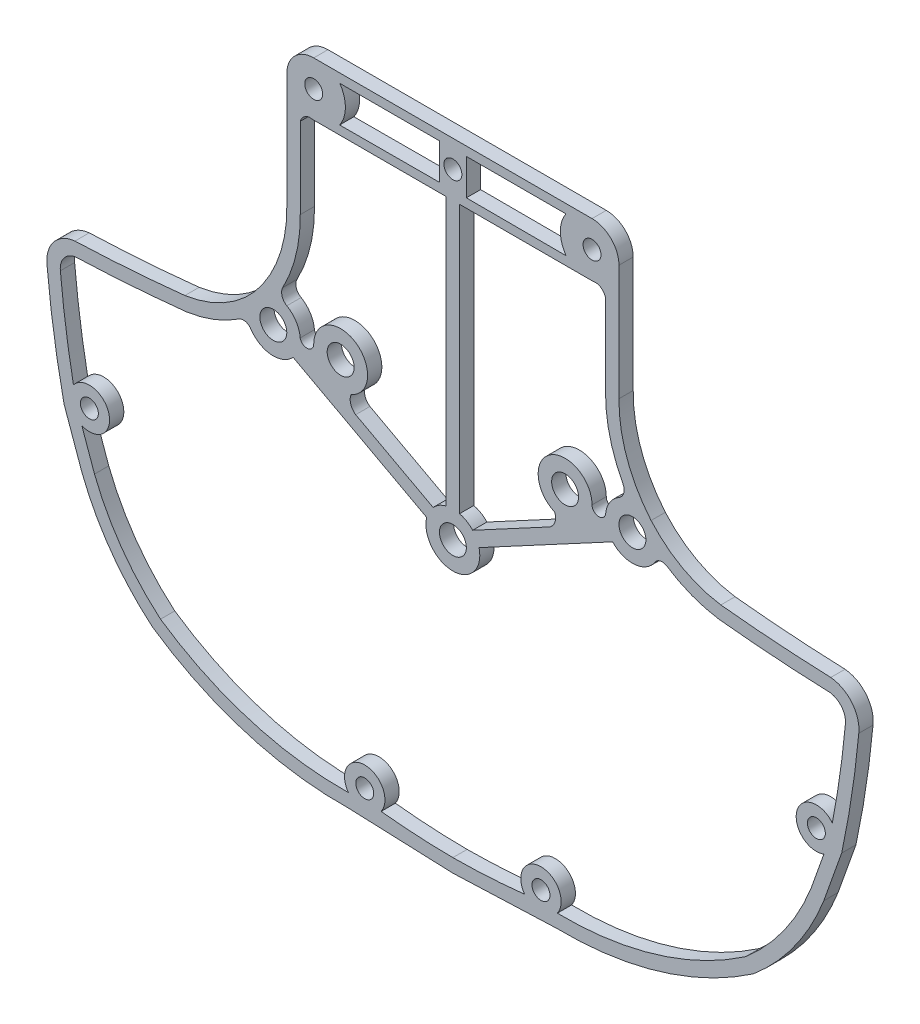
from build123d import *

# Parameters (mm, degrees)
SKETCH4_R           = 1
SKETCH4_R_2         = 1.5
SKETCH4_R_3         = 1.500000001
BOSS_EXTRUDE2_DEPTH = 1.5875


with BuildPart() as part:
    # Sketch4 → Boss-Extrude2 (new body)
    with BuildSketch(Plane.XY):
        with BuildLine():
            ThreePointArc((-33.472754103, -25.121469845), (-23.054804413, -30.112701264), (-11.610361031, -31.68457355))
            Line((-11.610361031, -31.68457355), (0, -32.144613372))
            Line((0, -32.144613372), (11.610361031, -31.68457355))
            ThreePointArc((11.610361031, -31.68457355), (23.054804413, -30.112701264), (33.472754103, -25.121469845))
            ThreePointArc((33.472754103, -25.121469845), (38.084735692, -20.128369992), (41.315395383, -14.148047401))
            Line((41.315395383, -14.148047401), (43.310324676, -8.545068137))
            ThreePointArc((43.310324676, -8.545068137), (44.448650445, -2.324461154), (45.212741618, 3.953110149))
            ThreePointArc((45.212741618, 3.953110149), (44.453814547, 6.519739723), (42.09374947, 7.782138432))
            ThreePointArc((42.09374947, 7.782138432), (35.962680023, 8.111048014), (29.846780415, 8.653234381))
            ThreePointArc((29.846780415, 8.653234381), (25.580679905, 10.088760175), (22.077124707, 12.914613823))
            ThreePointArc((22.077124707, 12.914613823), (19.390258386, 17.570844388), (18.500000009, 22.872464303))
            Line((18.500000009, 22.872464303), (18.500000009, 35.75))
            ThreePointArc((18.500000009, 35.75), (17.62132035, 37.87132035), (15.5, 38.750000009))
            Line((15.5, 38.750000009), (-15.5, 38.750000009))
            ThreePointArc((-15.5, 38.750000009), (-17.62132035, 37.87132035), (-18.500000009, 35.75))
            Line((-18.500000009, 35.75), (-18.500000009, 22.872464277))
            ThreePointArc((-18.500000009, 22.872464277), (-19.390258383, 17.570844381), (-22.07712469, 12.91461383))
            ThreePointArc((-22.07712469, 12.91461383), (-25.580679805, 10.088760216), (-29.846780215, 8.653234395))
            ThreePointArc((-29.846780215, 8.653234395), (-35.962679941, 8.111048017), (-42.093749505, 7.78213843))
            ThreePointArc((-42.093749505, 7.78213843), (-44.453814559, 6.519739711), (-45.212741618, 3.953110149))
            ThreePointArc((-45.212741618, 3.953110149), (-44.448650445, -2.324461154), (-43.310324676, -8.545068137))
            Line((-43.310324676, -8.545068137), (-41.315395383, -14.148047401))
            ThreePointArc((-41.315395383, -14.148047401), (-38.084735692, -20.128369992), (-33.472754103, -25.121469845))
        make_face()
        with Locations((-9.815163292, -28.866300371)):
            Circle(SKETCH4_R, mode=Mode.SUBTRACT)
        with Locations((-40.488991371, -7.557479081)):
            Circle(SKETCH4_R, mode=Mode.SUBTRACT)
        with BuildLine():
            Line((-39.916947455, -13.605513167), (-41.326325711, -9.6458687))
            ThreePointArc((-41.326325711, -9.6458687), (-38.316546684, -6.971830651), (-42.262559751, -6.172937569))
            ThreePointArc((-42.262559751, -6.172937569), (-43.119549374, -1.052504396), (-43.720300768, 4.104274139))
            ThreePointArc((-43.720300768, 4.104274139), (-43.306279922, 5.553180603), (-41.988991391, 6.284955247))
            ThreePointArc((-41.988991391, 6.284955247), (-35.815859297, 6.617706074), (-29.658025423, 7.164848598))
            ThreePointArc((-29.658025423, 7.164848598), (-26.630229039, 7.954390182), (-23.847155024, 9.384574043))
            ThreePointArc((-23.847155024, 9.384574043), (-23.125480938, 9.525676377), (-22.515405804, 9.115150267))
            ThreePointArc((-22.515405804, 9.115150267), (-20.254015304, 7.760773306), (-17.79651867, 8.714153732))
            Line((-17.79651867, 8.714153732), (-2.913646, 0.714609672))
            ThreePointArc((-2.913646, 0.714609672), (0, -3), (2.913646001, 0.714609672))
            Line((2.913646001, 0.714609672), (17.79651867, 8.714153732))
            ThreePointArc((17.79651867, 8.714153732), (20.254015126, 7.760773292), (22.515405609, 9.115149969))
            ThreePointArc((22.515405609, 9.115149969), (23.125480765, 9.52567634), (23.847155026, 9.384574041))
            ThreePointArc((23.847155026, 9.384574041), (26.630229041, 7.954390183), (29.658025423, 7.164848601))
            ThreePointArc((29.658025423, 7.164848601), (35.815859287, 6.617706075), (41.988991371, 6.284955244))
            ThreePointArc((41.988991371, 6.284955244), (43.306279914, 5.553180608), (43.720300768, 4.104274139))
            ThreePointArc((43.720300768, 4.104274139), (43.119549374, -1.052504396), (42.262559751, -6.172937569))
            ThreePointArc((42.262559751, -6.172937569), (38.316546684, -6.971830651), (41.326325712, -9.6458687))
            Line((41.326325712, -9.6458687), (39.916947456, -13.605513167))
            ThreePointArc((39.916947456, -13.605513167), (36.88563151, -19.226390572), (32.562542901, -23.926820768))
            ThreePointArc((32.562542901, -23.926820768), (22.58818115, -28.686629582), (11.638338487, -30.184834485))
            ThreePointArc((11.638338487, -30.184834485), (9.815163292, -26.616300371), (7.991988098, -30.184834485))
            ThreePointArc((7.991988098, -30.184834485), (4.00190894, -30.517536934), (0, -30.644609524))
            ThreePointArc((0, -30.644609524), (-4.00190894, -30.517536934), (-7.991988097, -30.184834485))
            ThreePointArc((-7.991988097, -30.184834485), (-9.815163292, -26.616300371), (-11.638338487, -30.184834485))
            ThreePointArc((-11.638338487, -30.184834485), (-22.58818115, -28.686629582), (-32.562542901, -23.926820768))
            ThreePointArc((-32.562542901, -23.926820768), (-36.88563151, -19.226390572), (-39.916947455, -13.605513167))
        make_face(mode=Mode.SUBTRACT)
        with Locations((9.815163292, -28.866300371)):
            Circle(SKETCH4_R, mode=Mode.SUBTRACT)
        Circle(SKETCH4_R_2, mode=Mode.SUBTRACT)
        with Locations((40.488991371, -7.557479081)):
            Circle(SKETCH4_R, mode=Mode.SUBTRACT)
        with Locations((-20.000000001, 10.750000001)):
            Circle(SKETCH4_R_3, mode=Mode.SUBTRACT)
        with Locations((-12.5, 11.133699629)):
            Circle(SKETCH4_R_2, mode=Mode.SUBTRACT)
        with BuildLine():
            ThreePointArc((-18.952977672, 14.865256843), (-17.471741936, 18.750329795), (-17.000000007, 22.881347914))
            Line((-17.000000007, 22.881347914), (-17.000000007, 31.885058019))
            ThreePointArc((-17.000000007, 31.885058019), (-16.616434483, 32.496276684), (-15.954980266, 32.784701868))
            ThreePointArc((-15.954980266, 32.784701868), (-15.728150861, 32.758688041), (-15.5, 32.749999991))
            Line((-15.5, 32.749999991), (-0.750000001, 32.749999991))
            Line((-0.750000001, 32.749999991), (-0.750000001, 2.90473751))
            ThreePointArc((-0.750000001, 2.90473751), (-1.539319977, 2.574974565), (-2.20348133, 2.035846268))
            Line((-2.20348133, 2.035846268), (-10.824171764, 6.669467376))
            ThreePointArc((-10.824171764, 6.669467376), (-11.357116861, 7.359839891), (-11.38326289, 8.231597352))
            ThreePointArc((-11.38326289, 8.231597352), (-11.323272383, 8.342575085), (-11.222961471, 8.41907763))
            ThreePointArc((-11.222961471, 8.41907763), (-10.892379956, 13.66659477), (-15.5, 11.133699629))
            ThreePointArc((-15.5, 11.133699629), (-16.184470968, 10.375365631), (-17.008738916, 10.978816797))
            ThreePointArc((-17.008738916, 10.978816797), (-17.458857736, 12.344551974), (-18.492829269, 13.343922973))
            ThreePointArc((-18.492829269, 13.343922973), (-18.498254435, 13.347040523), (-18.503662642, 13.3501874))
            ThreePointArc((-18.503662642, 13.3501874), (-19.027733875, 14.018926796), (-18.952977672, 14.865256843))
        make_face(mode=Mode.SUBTRACT)
        with Locations((-15.5, 35.75)):
            Circle(SKETCH4_R, mode=Mode.SUBTRACT)
        with BuildLine():
            Line((-12.592865853, 37.75), (-1.5, 37.75))
            Line((-1.5, 37.75), (-1.5, 33.75))
            Line((-1.5, 33.75), (-12.612506492, 33.721747011))
            ThreePointArc((-12.612506492, 33.721747011), (-11.971383706, 35.732795451), (-12.592865853, 37.75))
        make_face(mode=Mode.SUBTRACT)
        with Locations((12.5, 11.133699629)):
            Circle(SKETCH4_R_2, mode=Mode.SUBTRACT)
        with Locations((20, 10.75)):
            Circle(SKETCH4_R_2, mode=Mode.SUBTRACT)
        with BuildLine():
            Line((17.000000002, 31.88505801), (17.000000002, 22.881347906))
            ThreePointArc((17.000000002, 22.881347906), (17.471741935, 18.750329789), (18.952977675, 14.865256841))
            ThreePointArc((18.952977675, 14.865256841), (19.027733877, 14.018926793), (18.503662641, 13.350187397))
            ThreePointArc((18.503662641, 13.350187397), (18.498254436, 13.347040521), (18.492829272, 13.343922972))
            ThreePointArc((18.492829271, 13.343922974), (17.458857737, 12.344551974), (17.008738916, 10.978816797))
            ThreePointArc((17.008738916, 10.978816797), (16.184470968, 10.375365631), (15.5, 11.133699629))
            ThreePointArc((15.5, 11.133699629), (10.892379956, 13.66659477), (11.222961471, 8.41907763))
            ThreePointArc((11.222961471, 8.41907763), (11.323272383, 8.342575085), (11.38326289, 8.231597352))
            ThreePointArc((11.38326289, 8.231597352), (11.357116861, 7.359839891), (10.824171764, 6.669467376))
            Line((10.824171764, 6.669467376), (2.20348133, 2.035846268))
            ThreePointArc((2.20348133, 2.035846268), (1.539319976, 2.574974565), (0.749999999, 2.90473751))
            Line((0.749999999, 2.90473751), (0.749999999, 32.749999991))
            Line((0.749999999, 32.749999991), (15.5, 32.749999991))
            ThreePointArc((15.5, 32.749999991), (15.728150862, 32.758688041), (15.954980267, 32.784701869))
            ThreePointArc((15.954980267, 32.784701869), (16.616434482, 32.496276679), (17.000000002, 31.88505801))
        make_face(mode=Mode.SUBTRACT)
        with Locations((0, 35.75)):
            Circle(SKETCH4_R, mode=Mode.SUBTRACT)
        with BuildLine():
            Line((1.5, 33.75), (1.5, 37.75))
            Line((1.5, 37.75), (12.592865854, 37.75))
            ThreePointArc((12.592865854, 37.75), (11.971383706, 35.732795451), (12.612506492, 33.721747011))
            Line((12.612506492, 33.721747011), (1.5, 33.75))
        make_face(mode=Mode.SUBTRACT)
        with Locations((15.5, 35.75)):
            Circle(SKETCH4_R, mode=Mode.SUBTRACT)
    extrude(amount=BOSS_EXTRUDE2_DEPTH)


solid = part.part
